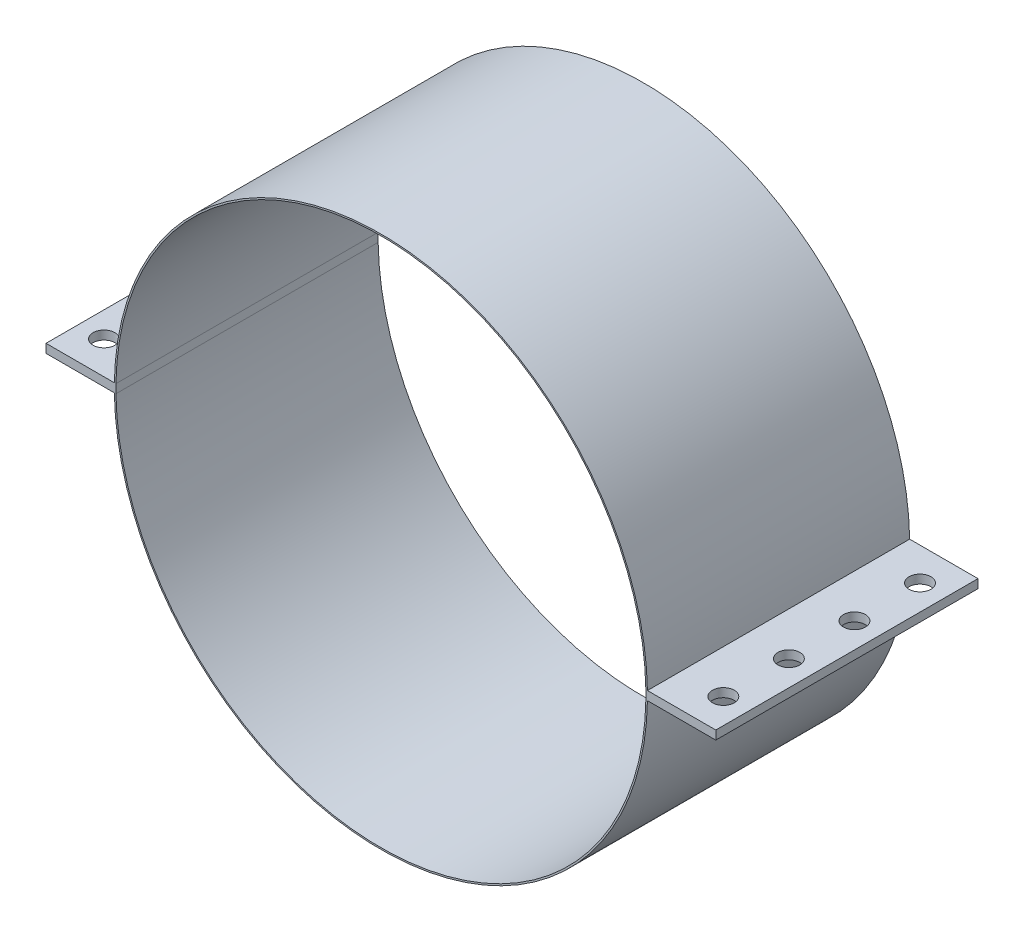
from build123d import *

# Parameters (mm, degrees)
SKETCH1_R           = 77.47
SKETCH1_R_2         = 77.0128
BOSS_EXTRUDE1_DEPTH = 76.2
SKETCH2_W           = 20.32
SKETCH2_H           = 2.54
BOSS_EXTRUDE2_DEPTH = 76.2
SKETCH3_R           = 3.175
CUT_EXTRUDE3_DEPTH  = 2.54


with BuildPart() as part:
    # Sketch1 → Boss-Extrude1 (new body)
    with BuildSketch(Plane.XY):
        Circle(SKETCH1_R)
        Circle(SKETCH1_R_2, mode=Mode.SUBTRACT)
    extrude(amount=BOSS_EXTRUDE1_DEPTH)

    # Sketch2 → Boss-Extrude2 (add)
    with BuildSketch(Plane.XY.offset(76.2)):
        with Locations((87.162327652, 0)):
            Rectangle(SKETCH2_W, SKETCH2_H)
        with Locations((-87.162327652, 0)):
            Rectangle(SKETCH2_W, SKETCH2_H)
    extrude(amount=-BOSS_EXTRUDE2_DEPTH)

    # Sketch3 → Cut-Extrude3 (cut)
    with BuildSketch(Plane(origin=(0, 1.27, 0), x_dir=(1, 0, 0), z_dir=(0, 1, 0))):
        with Locations((89.995251464, -9.525)):
            Circle(SKETCH3_R)
        with Locations((89.995251464, -28.575)):
            Circle(SKETCH3_R)
        with Locations((89.995251464, -47.625)):
            Circle(SKETCH3_R)
        with Locations((89.995251464, -66.675)):
            Circle(SKETCH3_R)
        with Locations((-89.995251464, -9.525)):
            Circle(SKETCH3_R)
        with Locations((-89.995251464, -28.575)):
            Circle(SKETCH3_R)
        with Locations((-89.995251464, -47.625)):
            Circle(SKETCH3_R)
        with Locations((-89.995251464, -66.675)):
            Circle(SKETCH3_R)
    extrude(amount=-CUT_EXTRUDE3_DEPTH, mode=Mode.SUBTRACT)


solid = part.part
